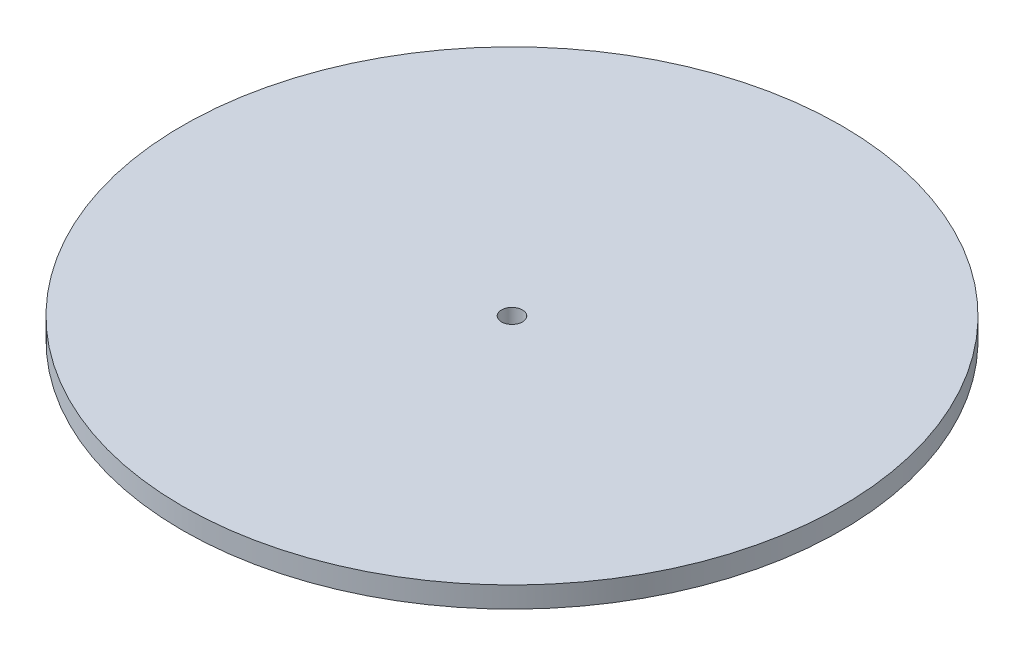
from build123d import *

# Parameters (mm, degrees)
SKETCH1_R           = 400
SKETCH1_R_2         = 12.7
BOSS_EXTRUDE1_DEPTH = 25.4


with BuildPart() as part:
    # Sketch1 → Boss-Extrude1 (new body)
    with BuildSketch(Plane(origin=(0, 0, 0), x_dir=(1, 0, 0), z_dir=(0, 1, 0))):
        with Locations(Location((0, 0, 0), (0, 0, 270))):  # turned: the seam where the file's is
            Circle(SKETCH1_R)
        with Locations(Location((0, 0, 0), (0, 0, 270))):  # turned: the seam where the file's is
            Circle(SKETCH1_R_2, mode=Mode.SUBTRACT)
    extrude(amount=BOSS_EXTRUDE1_DEPTH)


solid = part.part
